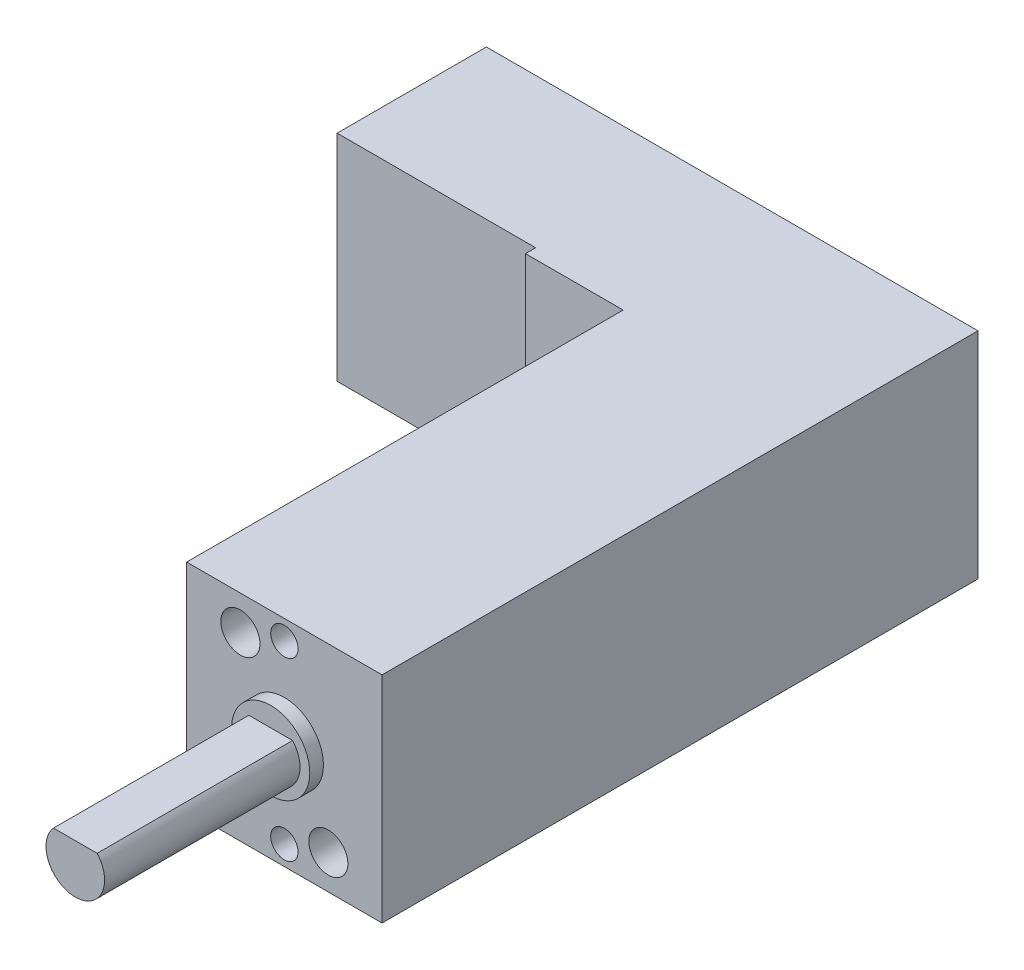
from build123d import *

# Parameters (mm, degrees)
SKETCH1_W           = 15
SKETCH1_H           = 11
BOSS_EXTRUDE1_DEPTH = 21.5
SKETCH2_W           = 10
SKETCH2_H           = 11
BOSS_EXTRUDE2_DEPTH = 9
SKETCH3_R           = 2
BOSS_EXTRUDE3_DEPTH = 0.7
SKETCH4_R           = 1.5
BOSS_EXTRUDE4_DEPTH = 10
CUT_EXTRUDE1_DEPTH  = 10
SKETCH6_R           = 0.7
SKETCH6_R_2         = 1
CUT_EXTRUDE2_DEPTH  = 3
SKETCH7_W           = 7.64
SKETCH7_H           = 11
BOSS_EXTRUDE5_DEPTH = 10.16
SKETCH8_W           = 5
SKETCH8_H           = 13.3399974
CUT_EXTRUDE3_DEPTH  = 11


with BuildPart() as part:
    # Sketch1 → Boss-Extrude1 (new body)
    with BuildSketch(Plane.XY):
        Rectangle(SKETCH1_W, SKETCH1_H)
    extrude(amount=BOSS_EXTRUDE1_DEPTH)

    # Sketch2 → Boss-Extrude2 (add)
    with BuildSketch(Plane.XY.offset(21.5)):
        with Locations((2.5, 0)):
            Rectangle(SKETCH2_W, SKETCH2_H)
    extrude(amount=BOSS_EXTRUDE2_DEPTH)

    # Sketch3 → Boss-Extrude3 (add)
    with BuildSketch(Plane.XY.offset(30.5)):
        with Locations((2.5, 0)):
            Circle(SKETCH3_R)
    extrude(amount=BOSS_EXTRUDE3_DEPTH)

    # Sketch4 → Boss-Extrude4 (add)
    with BuildSketch(Plane.XY.offset(31.2)):
        with Locations((2.5, 0)):
            Circle(SKETCH4_R)
    extrude(amount=BOSS_EXTRUDE4_DEPTH)

    # Sketch5 → Cut-Extrude1 (cut)
    with BuildSketch(Plane.XY.offset(41.2)):
        with BuildLine():
            Line((1.381966011, 1), (3.618033989, 1))
            ThreePointArc((3.618033989, 1), (2.5, 1.5), (1.381966011, 1))
        make_face()
    extrude(amount=-CUT_EXTRUDE1_DEPTH, mode=Mode.SUBTRACT)

    # Sketch6 → Cut-Extrude2 (cut)
    with BuildSketch(Plane.XY.offset(30.5)):
        with Locations((2.5, 4.5)):
            Circle(SKETCH6_R)
        with Locations((2.5, -4.5)):
            Circle(SKETCH6_R)
        with Locations((4.75, -3.75)):
            Circle(SKETCH6_R_2)
        with Locations((0.25, 3.75)):
            Circle(SKETCH6_R_2)
    extrude(amount=-CUT_EXTRUDE2_DEPTH, mode=Mode.SUBTRACT)

    # Sketch7 → Boss-Extrude5 (add)
    with BuildSketch(Plane.ZY.offset(7.5)):
        with Locations((3.82, 0)):
            Rectangle(SKETCH7_W, SKETCH7_H)
    extrude(amount=BOSS_EXTRUDE5_DEPTH)

    # Sketch8 → Cut-Extrude3 (cut)
    with BuildSketch(Plane.XZ.offset(5.5)):
        with Locations((-5, 14.8300013)):
            Rectangle(SKETCH8_W, SKETCH8_H)
    extrude(amount=-CUT_EXTRUDE3_DEPTH, mode=Mode.SUBTRACT)


solid = part.part
